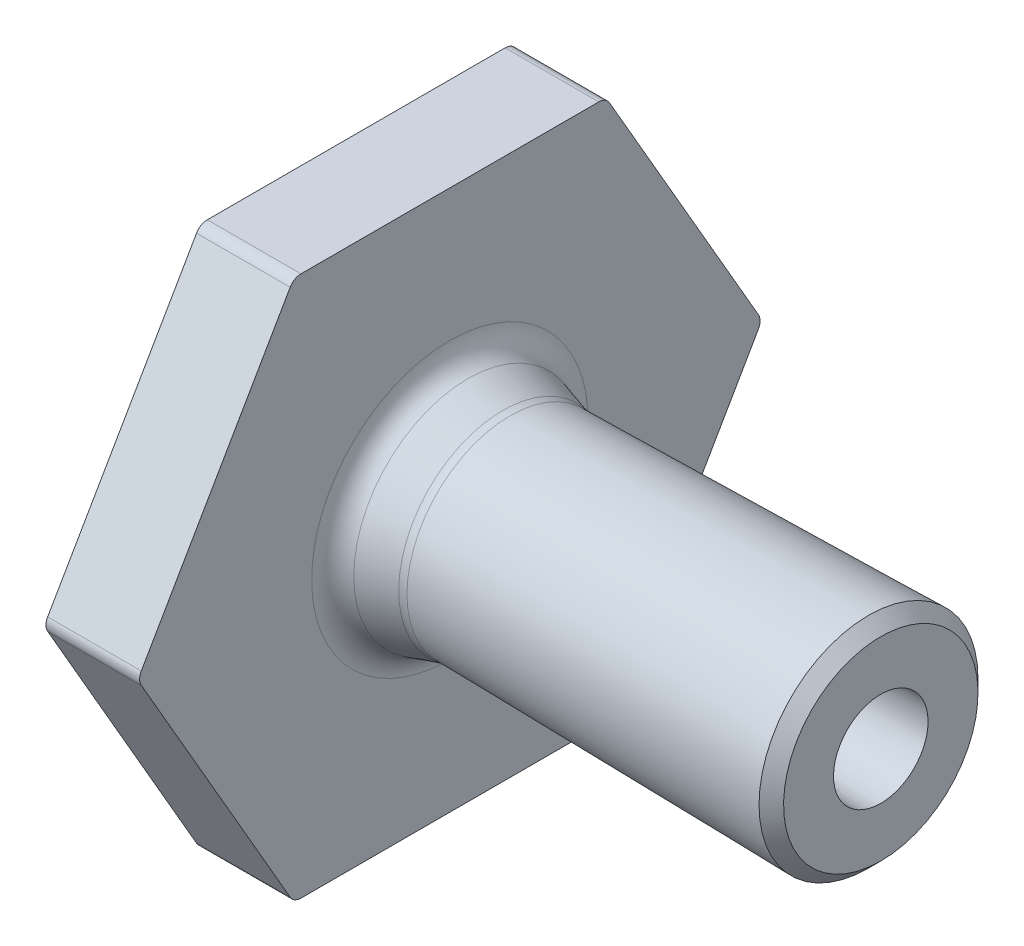
from build123d import *

# Parameters (mm, degrees)
FILLET4_R               = 3
CHAMFER1_SIZE2          = 0.393197641
CHAMFER1_SIZE           = 0.4
CUT_EXTRUDE1_DEPTH      = 14.804133806
CUT_EXTRUDE1_DEPTH_BACK = 8.0000001
FILLET5_R               = 0.4
FILLET6_R               = 0.8
FILLET7_R               = 0.2


with BuildPart() as part:
    # Sketch1 → Revolve1 (revolve)
    with BuildSketch(Plane.XY):
        Polygon((0, 1.825), (6.718918331, 1.825), (8.549810914, 1.3), (20.804133706, 1.5139), (20.804133706, 3.514204656), (8.813762579, 3.30491195), (7, 3.825), (7, 10), (4, 10), (4, 2.625), (0, 2.625), align=None)
    revolve(axis=Axis((0, 0, 0), (1, 0, 0)))

    # Fillet4
    fillet4_edges = [part.edges().sort_by_distance(p)[0] for p in [
        (8.549810914, -1.3, 0),
        (6.718918331, -1.825, 0),
    ]]
    fillet(fillet4_edges, radius=FILLET4_R)

    # Chamfer1
    chamfer1_edges = [part.edges().sort_by_distance(p)[0] for p in [
        (20.804133706, -3.514204656, 0),
    ]]
    chamfer(chamfer1_edges, length=CHAMFER1_SIZE, length2=CHAMFER1_SIZE2)

    # Sketch2 → Cut-Extrude1 (cut, two sides)
    with BuildSketch(Plane(origin=(7, 0, 0), x_dir=(0, 0, -1), z_dir=(1, 0, 0))) as cut_extrude1_sk:
        with BuildLine():
            Line((-10, 0), (-5, 8.660254038))
            ThreePointArc((-5, 8.660254038), (-8.660254038, 5), (-10, 0))
        make_face()
        with BuildLine():
            Line((-5, 8.660254038), (5, 8.660254038))
            ThreePointArc((5, 8.660254038), (0, 10), (-5, 8.660254038))
        make_face()
        with BuildLine():
            Line((5, 8.660254038), (10, 0))
            ThreePointArc((10, 0), (8.660254038, 5), (5, 8.660254038))
        make_face()
        with BuildLine():
            ThreePointArc((-10, 0), (-8.660254038, -5), (-5, -8.660254038))
            Line((-5, -8.660254038), (-10, 0))
        make_face()
        with BuildLine():
            ThreePointArc((-5, -8.660254038), (0, -10), (5, -8.660254038))
            Line((5, -8.660254038), (-5, -8.660254038))
        make_face()
        with BuildLine():
            ThreePointArc((5, -8.660254038), (8.660254038, -5), (10, 0))
            Line((10, 0), (5, -8.660254038))
        make_face()
    extrude(amount=CUT_EXTRUDE1_DEPTH, mode=Mode.SUBTRACT)
    extrude(cut_extrude1_sk.sketch, amount=-CUT_EXTRUDE1_DEPTH_BACK, mode=Mode.SUBTRACT)

    # Fillet5
    fillet5_edges = [part.edges().sort_by_distance(p)[0] for p in [
        (5.5, 8.660254038, 5),
        (5.5, 0, 10),
        (5.5, 0, -10),
        (5.5, 8.660254038, -5),
        (5.5, -8.660254038, 5),
        (5.5, -8.660254038, -5),
    ]]
    fillet(fillet5_edges, radius=FILLET5_R)

    # Fillet6
    fillet6_edges = [part.edges().sort_by_distance(p)[0] for p in [
        (7, -3.825, 0),
        (8.813762579, -3.30491195, 0),
    ]]
    fillet(fillet6_edges, radius=FILLET6_R)

    # Fillet7
    fillet7_edges = [part.edges().sort_by_distance(p)[0] for p in [
        (4, -2.625, 0),
    ]]
    fillet(fillet7_edges, radius=FILLET7_R)


solid = part.part
